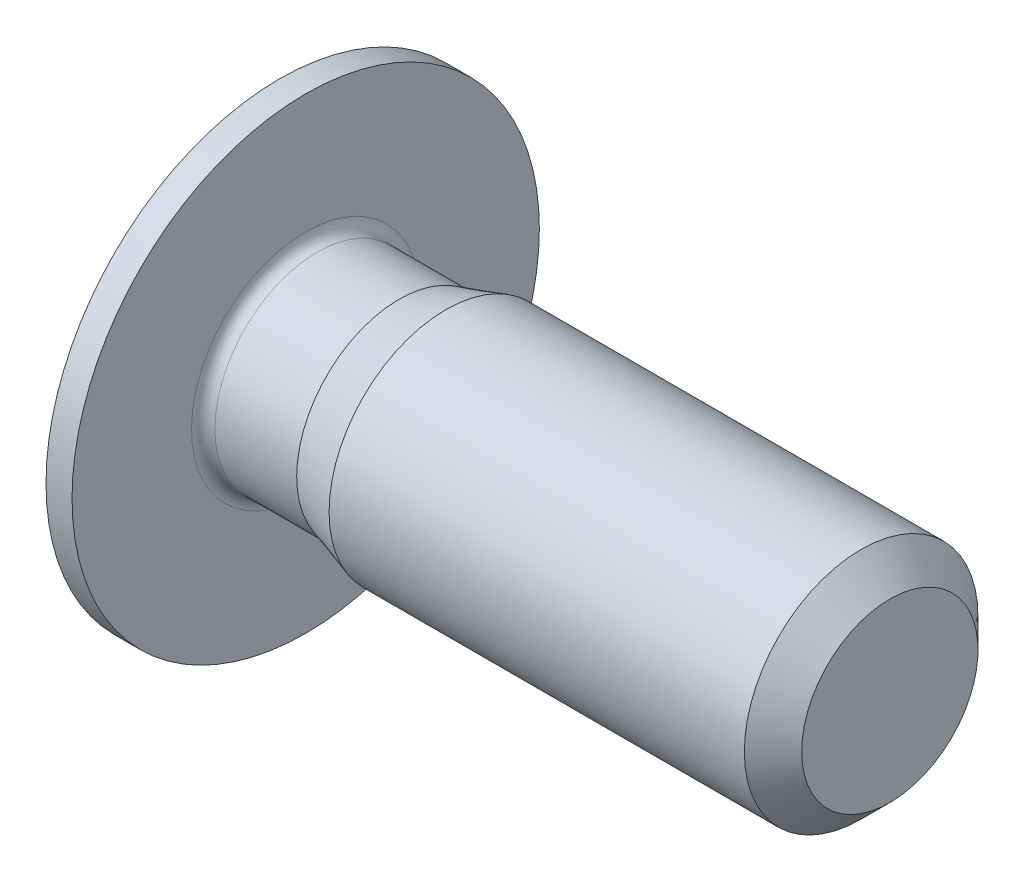
from build123d import *

# Parameters (mm, degrees)
CUT_EXTRUDE1_DEPTH = 1.2


with BuildPart() as part:
    # Sketch1 → Revolve1 (revolve)
    with BuildSketch(Plane.XY):
        with BuildLine():
            Line((-0.5, 0), (-0.5, 1.52))
            Line((-0.5, 1.52), (-0.222871871, 2))
            Line((-0.222871871, 2), (0, 2))
            Line((0, 2), (0, 0.97725))
            ThreePointArc((0, 0.97725), (0.029289322, 0.906539322), (0.1, 0.87725))
            Line((0.1, 0.87725), (0.8, 0.87725))
            Line((0.8, 0.87725), (1.2, 1))
            Line((1.2, 1), (4.7545, 1))
            Line((4.7545, 1), (5, 0.7545))
            Line((5, 0.7545), (5, 0))
            Line((5, 0), (-0.5, 0))
        make_face()
    revolve(axis=Axis((5, 0, 0), (-1, 0, 0)))

    # Sketch2 → Cut-Revolve1 (revolve, cut)
    with BuildSketch(Plane.XY):
        Polygon((-0.5, 0), (-0.5, 0.65), (0.7, 0.65), (1.075277675, 0), align=None)
    revolve(axis=Axis((1.075277675, 0, 0), (-1, 0, 0)), mode=Mode.SUBTRACT)

    # Sketch3 → Cut-Extrude1 (cut)
    with BuildSketch(Plane(origin=(-0.5, 0, 0), x_dir=(0, 0, -1), z_dir=(1, 0, 0))):
        Polygon((-0.65, -0.375277675), (0, -0.75055535), (0.65, -0.375277675), (0.65, 0.375277675), (0, 0.75055535), (-0.65, 0.375277675), align=None)
    extrude(amount=CUT_EXTRUDE1_DEPTH, mode=Mode.SUBTRACT)


solid = part.part
